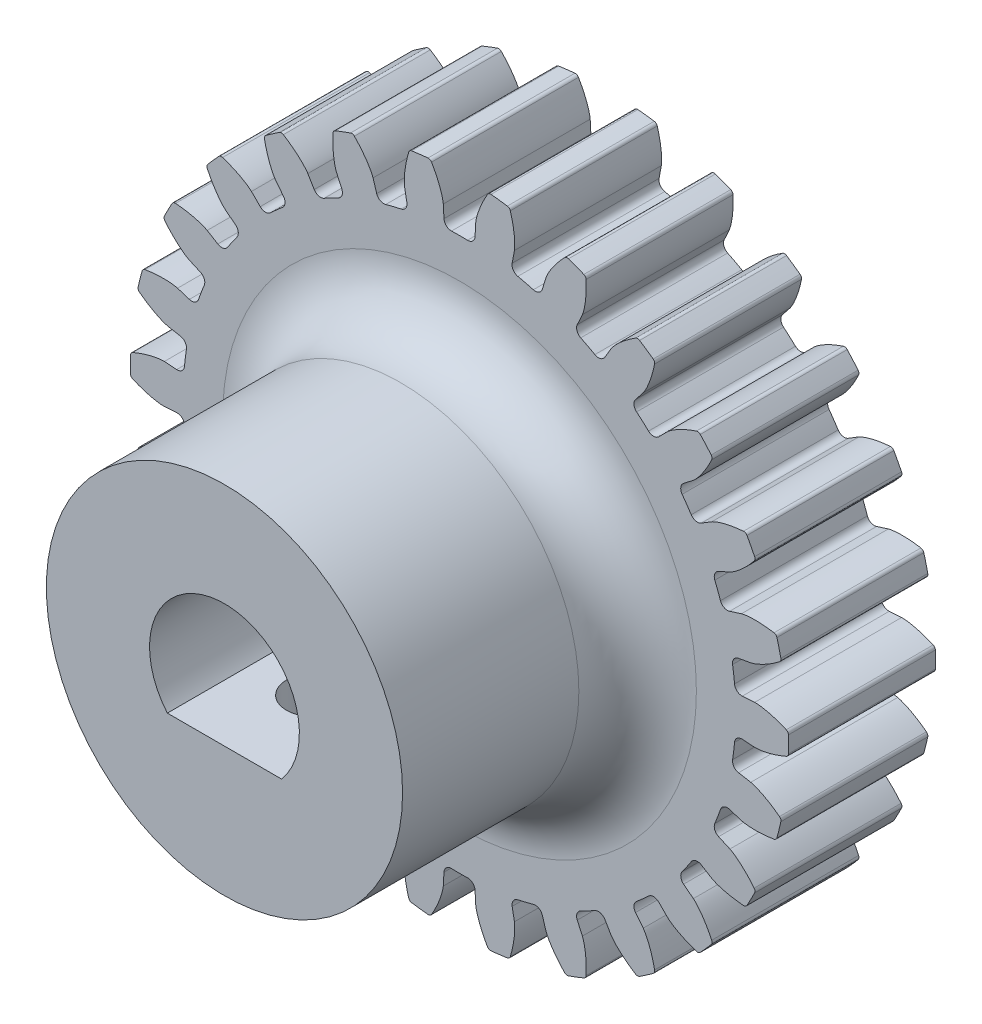
from build123d import *

# Parameters (mm, degrees)
SKETCH1_R                                 = 14.224
BOSS_EXTRUDE1_DEPTH                       = 6.35
CUT_EXTRUDE_DCLTBC_DEPTH                  = 22.094237412
FILLET_TIP_DCLTBC_R                       = 0.158798261
FILLET_ROOT_DCLTBC_R                      = 0.317596521
CIRPATTERN_DCLTBC_COUNT                   = 26
FILLET_TIP_DCLTBC_OF_CIRPATTERN_DCLTBC_R  = 0.158798261
FILLET_ROOT_DCLTBC_OF_CIRPATTERN_DCLTBC_R = 0.317596521
SKETCH4_R                                 = 5.159375
CUT_EXTRUDE2_DEPTH                        = 22.05078392
SKETCH5_R                                 = 7.699375
BOSS_EXTRUDE2_DEPTH                       = 10.16
FILLET1_R                                 = 2.54
F_4_40_TAPPED_HOLE1_D                     = 2.2606
F_4_40_TAPPED_HOLE1_DEPTH                 = 5.603875
F_4_40_TAPPED_HOLE1_CSINK_D               = 3.5306
F_4_40_TAPPED_HOLE1_CSINK_ANGLE           = 100


with BuildPart() as part:
    # Sketch1 → Boss-Extrude1 (new body)
    with BuildSketch(Plane.XY):
        Circle(SKETCH1_R)
    extrude(amount=BOSS_EXTRUDE1_DEPTH)

    # DCLTBC → Cut-Extrude-DCLTBC (cut, through all)
    with BuildSketch(Plane.XY):
        with BuildLine():
            Line((-0.701291918, 12.768049121), (-0.654714195, 11.920033277))
            ThreePointArc((-0.654714195, 11.920033277), (0, 11.938), (0.654714195, 11.920033277))
            Line((0.654714195, 11.920033277), (0.701291918, 12.768049121))
            add(Edge.make_bspline(
                [(0.701291918, 12.768049121), (0.701438055, 12.770288138), (0.701919445, 12.776563901), (0.703111941, 12.788412019), (0.705458923, 12.807720305), (0.70903905, 12.832283995), (0.714343616, 12.863986278), (0.721463561, 12.901268701), (0.73020086, 12.942170955), (0.740691816, 12.98659091), (0.752029246, 13.030831956), (0.764149894, 13.074891954), (0.776955412, 13.118714645), (0.793331549, 13.171713716), (0.814169762, 13.23514485), (0.840277589, 13.309101661), (0.871954349, 13.392754425), (0.906448964, 13.477758228), (0.942208094, 13.561189909), (0.980427141, 13.645231225), (1.018886177, 13.726364112), (1.060974399, 13.810362734), (1.100912409, 13.887758741), (1.148027672, 13.974155638), (1.186741813, 14.043787426), (1.228710553, 14.115446774), (1.249428806, 14.150283733), (1.260140073, 14.168070546)],
                knots=[0, 0, 0, 0, 0, 0.005376749, 0.015083688, 0.02853182, 0.04661014, 0.064854849, 0.092110526, 0.119476176, 0.146842496, 0.174208854, 0.201574956, 0.228941013, 0.256307345, 0.307035032, 0.361767352, 0.416499661, 0.471231937, 0.525964282, 0.580696616, 0.635428982, 0.690161387, 0.744893688, 0.799626082, 0.854358407, 0.909090914, 0.909090914, 0.909090914, 0.909090914, 0.909090914], degree=4))
            ThreePointArc((1.260140073, 14.168070546), (0, 14.224), (-1.260140073, 14.168070546))
            add(Edge.make_bspline(
                [(-0.701291918, 12.768049121), (-0.701438055, 12.770288138), (-0.701919445, 12.776563901), (-0.703111941, 12.788412019), (-0.705458923, 12.807720305), (-0.70903905, 12.832283995), (-0.714343616, 12.863986278), (-0.721463561, 12.901268701), (-0.73020086, 12.942170955), (-0.740691816, 12.98659091), (-0.752029246, 13.030831956), (-0.764149894, 13.074891954), (-0.776955412, 13.118714645), (-0.793331549, 13.171713716), (-0.814169762, 13.23514485), (-0.840277589, 13.309101661), (-0.871954349, 13.392754425), (-0.906448964, 13.477758228), (-0.942208094, 13.561189909), (-0.980427141, 13.645231225), (-1.018886177, 13.726364112), (-1.060974399, 13.810362734), (-1.100912409, 13.887758741), (-1.148027672, 13.974155638), (-1.186741813, 14.043787426), (-1.228710553, 14.115446774), (-1.249428806, 14.150283733), (-1.260140073, 14.168070546)],
                knots=[0, 0, 0, 0, 0, 0.005376749, 0.015083688, 0.02853182, 0.04661014, 0.064854849, 0.092110526, 0.119476176, 0.146842496, 0.174208854, 0.201574956, 0.228941013, 0.256307345, 0.307035032, 0.361767352, 0.416499661, 0.471231937, 0.525964282, 0.580696616, 0.635428982, 0.690161387, 0.744893688, 0.799626082, 0.854358407, 0.909090914, 0.909090914, 0.909090914, 0.909090914, 0.909090914], degree=4))
        make_face()
    cut_extrude_dcltbc = extrude(amount=CUT_EXTRUDE_DCLTBC_DEPTH, mode=Mode.SUBTRACT)

    # Fillet-Tip-DCLTBC
    fillet_tip_dcltbc_edges = [part.edges().sort_by_distance(p)[0] for p in [
        (1.260140073, 14.168070546, 3.175),
        (-1.260140073, 14.168070546, 3.175),
    ]]
    fillet(fillet_tip_dcltbc_edges, radius=FILLET_TIP_DCLTBC_R)

    # Fillet-Root-DCLTBC
    fillet_root_dcltbc_edges = [part.edges().sort_by_distance(p)[0] for p in [
        (0.654714195, 11.920033277, 3.175),
        (-0.654714195, 11.920033277, 3.175),
    ]]
    fillet(fillet_root_dcltbc_edges, radius=FILLET_ROOT_DCLTBC_R)

    # CirPattern-DCLTBC: Cut-Extrude-DCLTBC ×26 about axis
    cirpattern_dcltbc_axis = Axis((0, 0, 6.35), (0, 0, 1))
    for i in range(1, CIRPATTERN_DCLTBC_COUNT):
        add(cut_extrude_dcltbc.rotate(cirpattern_dcltbc_axis, i * 360 / CIRPATTERN_DCLTBC_COUNT), mode=Mode.SUBTRACT)

    # Fillet-Tip-DCLTBC of CirPattern-DCLTBC
    fillet_tip_dcltbc_of_cirpattern_dcltbc_edges = [part.edges().sort_by_distance(p)[0] for p in [
        (-2.167118522, 14.057943424, 3.175),
        (-4.614163907, 13.454800907, 3.175),
        (-5.468432065, 13.130819729, 3.175),
        (-7.700029306, 11.959587145, 3.175),
        (-8.451940214, 11.440580519, 3.175),
        (-10.338396991, 9.76932565, 3.175),
        (-10.944252319, 9.085456355, 3.175),
        (-12.375934621, 7.011306458, 3.175),
        (-12.80052426, 6.202318492, 3.175),
        (-13.694227916, 3.84581562, 3.175),
        (-13.912876259, 2.958724422, 3.175),
        (-14.216662461, 0.456819957, 3.175),
        (-14.216662461, -0.456819957, 3.175),
        (-13.912876259, -2.958724422, 3.175),
        (-13.694227916, -3.84581562, 3.175),
        (-12.80052426, -6.202318492, 3.175),
        (-12.375934621, -7.011306458, 3.175),
        (-10.944252319, -9.085456355, 3.175),
        (-10.338396991, -9.76932565, 3.175),
        (-8.451940214, -11.440580519, 3.175),
        (-7.700029306, -11.959587145, 3.175),
        (-5.468432065, -13.130819729, 3.175),
        (-4.614163907, -13.454800907, 3.175),
        (-2.167118522, -14.057943424, 3.175),
        (-1.260140073, -14.168070546, 3.175),
        (1.260140073, -14.168070546, 3.175),
        (2.167118522, -14.057943424, 3.175),
        (4.614163907, -13.454800907, 3.175),
        (5.468432065, -13.130819729, 3.175),
        (7.700029306, -11.959587145, 3.175),
        (8.451940214, -11.440580519, 3.175),
        (10.338396991, -9.76932565, 3.175),
        (10.944252319, -9.085456355, 3.175),
        (12.375934621, -7.011306458, 3.175),
        (12.80052426, -6.202318492, 3.175),
        (13.694227916, -3.84581562, 3.175),
        (13.912876259, -2.958724422, 3.175),
        (14.216662461, -0.456819957, 3.175),
        (14.216662461, 0.456819957, 3.175),
        (13.912876259, 2.958724422, 3.175),
        (13.694227916, 3.84581562, 3.175),
        (12.80052426, 6.202318492, 3.175),
        (12.375934621, 7.011306458, 3.175),
        (10.944252319, 9.085456355, 3.175),
        (10.338396991, 9.76932565, 3.175),
        (8.451940214, 11.440580519, 3.175),
        (7.700029306, 11.959587145, 3.175),
        (5.468432065, 13.130819729, 3.175),
        (4.614163907, 13.454800907, 3.175),
        (2.167118522, 14.057943424, 3.175),
    ]]
    fillet(fillet_tip_dcltbc_of_cirpattern_dcltbc_edges, radius=FILLET_TIP_DCLTBC_OF_CIRPATTERN_DCLTBC_R)

    # Fillet-Root-DCLTBC of CirPattern-DCLTBC
    fillet_root_dcltbc_of_cirpattern_dcltbc_edges = [part.edges().sort_by_distance(p)[0] for p in [
        (-2.216961292, 11.730342136, 3.175),
        (-3.488340072, 11.416975411, 3.175),
        (-4.959795047, 10.858926148, 3.175),
        (-6.119236304, 10.250404434, 3.175),
        (-7.414383541, 9.356428844, 3.175),
        (-8.394504765, 8.488117209, 3.175),
        (-9.438075015, 7.310169903, 3.175),
        (-10.181915121, 6.232531465, 3.175),
        (-10.913259874, 4.83907046, 3.175),
        (-11.37758958, 3.614733647, 3.175),
        (-11.754205738, 2.086741831, 3.175),
        (-11.912039889, 0.786860649, 3.175),
        (-11.912039889, -0.786860649, 3.175),
        (-11.754205738, -2.086741831, 3.175),
        (-11.37758958, -3.614733647, 3.175),
        (-10.913259874, -4.83907046, 3.175),
        (-10.181915121, -6.232531465, 3.175),
        (-9.438075015, -7.310169903, 3.175),
        (-8.394504765, -8.488117209, 3.175),
        (-7.414383541, -9.356428844, 3.175),
        (-6.119236304, -10.250404434, 3.175),
        (-4.959795047, -10.858926148, 3.175),
        (-3.488340072, -11.416975411, 3.175),
        (-2.216961292, -11.730342136, 3.175),
        (-0.654714195, -11.920033277, 3.175),
        (0.654714195, -11.920033277, 3.175),
        (2.216961292, -11.730342136, 3.175),
        (3.488340072, -11.416975411, 3.175),
        (4.959795047, -10.858926148, 3.175),
        (6.119236304, -10.250404434, 3.175),
        (7.414383541, -9.356428844, 3.175),
        (8.394504765, -8.488117209, 3.175),
        (9.438075015, -7.310169903, 3.175),
        (10.181915121, -6.232531465, 3.175),
        (10.913259874, -4.83907046, 3.175),
        (11.37758958, -3.614733647, 3.175),
        (11.754205738, -2.086741831, 3.175),
        (11.912039889, -0.786860649, 3.175),
        (11.912039889, 0.786860649, 3.175),
        (11.754205738, 2.086741831, 3.175),
        (11.37758958, 3.614733647, 3.175),
        (10.913259874, 4.83907046, 3.175),
        (10.181915121, 6.232531465, 3.175),
        (9.438075015, 7.310169903, 3.175),
        (8.394504765, 8.488117209, 3.175),
        (7.414383541, 9.356428844, 3.175),
        (6.119236304, 10.250404434, 3.175),
        (4.959795047, 10.858926148, 3.175),
        (3.488340072, 11.416975411, 3.175),
        (2.216961292, 11.730342136, 3.175),
    ]]
    fillet(fillet_root_dcltbc_of_cirpattern_dcltbc_edges, radius=FILLET_ROOT_DCLTBC_OF_CIRPATTERN_DCLTBC_R)

    # Sketch4 → Cut-Extrude2 (cut, through all)
    with BuildSketch(Plane.XY.offset(6.35)):
        Circle(SKETCH4_R)
        with BuildLine():
            ThreePointArc((2.469162206, -2.0955), (0, 3.2385), (-2.469162206, -2.0955))
            Line((-2.469162206, -2.0955), (2.469162206, -2.0955))
        make_face(mode=Mode.SUBTRACT)
        with BuildLine():
            Line((-2.469162206, -2.0955), (2.469162206, -2.0955))
            ThreePointArc((2.469162206, -2.0955), (0, 3.2385), (-2.469162206, -2.0955))
        make_face()
    extrude(amount=-CUT_EXTRUDE2_DEPTH, mode=Mode.SUBTRACT)

    # Sketch5 → Boss-Extrude2 (add)
    with BuildSketch(Plane.XY.offset(6.35)):
        Circle(SKETCH5_R)
        with BuildLine():
            Line((-2.469162206, -2.0955), (2.469162206, -2.0955))
            ThreePointArc((2.469162206, -2.0955), (0, 3.2385), (-2.469162206, -2.0955))
        make_face(mode=Mode.SUBTRACT)
    extrude(amount=BOSS_EXTRUDE2_DEPTH)

    # Fillet1
    fillet1_edges = [part.edges().sort_by_distance(p)[0] for p in [
        (-7.699375, 0, 6.35),
    ]]
    fillet(fillet1_edges, radius=FILLET1_R)

    # #4-40 Tapped Hole1
    with Locations(Plane(origin=(0, -7.699375, 16.51), x_dir=(-1, 0, 0), z_dir=(0, -1, 0))):
        with Locations((0, 3.81)):
            CounterSinkHole(F_4_40_TAPPED_HOLE1_D / 2, F_4_40_TAPPED_HOLE1_CSINK_D / 2, depth=F_4_40_TAPPED_HOLE1_DEPTH, counter_sink_angle=F_4_40_TAPPED_HOLE1_CSINK_ANGLE)


solid = part.part
